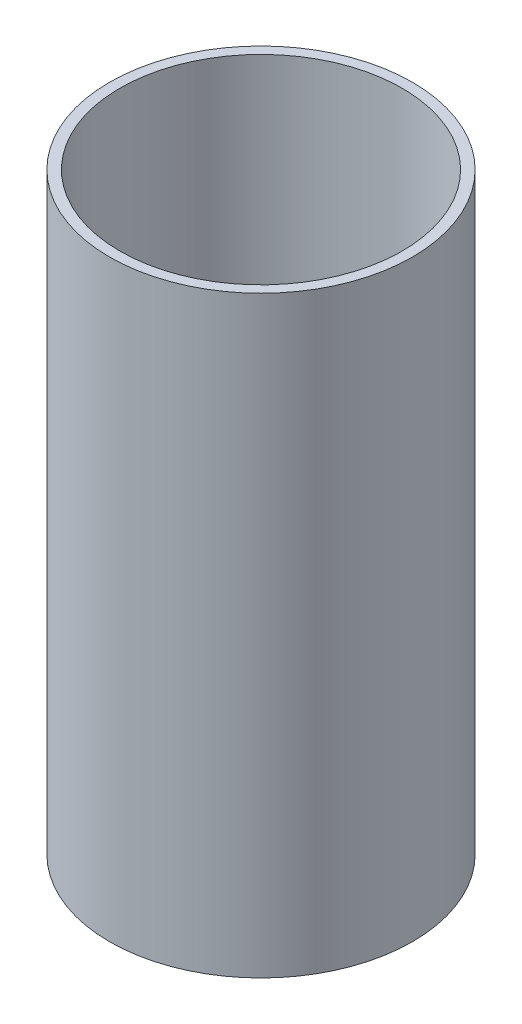
from build123d import *

# Parameters (mm, degrees)
SKETCH1_R           = 19.15
SKETCH1_R_2         = 17.85
BOSS_EXTRUDE1_DEPTH = 75


with BuildPart() as part:
    # Sketch1 → Boss-Extrude1 (new body)
    with BuildSketch(Plane(origin=(0, 0, 0), x_dir=(1, 0, 0), z_dir=(0, 1, 0))):
        Circle(SKETCH1_R)
        Circle(SKETCH1_R_2, mode=Mode.SUBTRACT)
    extrude(amount=BOSS_EXTRUDE1_DEPTH)


solid = part.part
